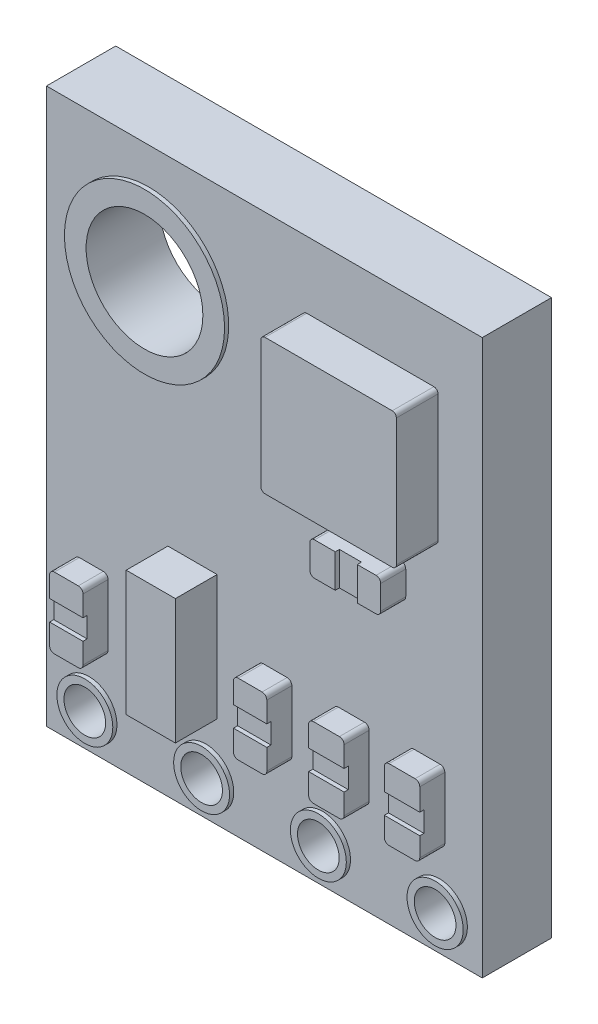
from build123d import *

# Parameters (mm, degrees)
CROQUIS1_W              = 10.45
CROQUIS1_H              = 13.3
CROQUIS1_R              = 1.4
SALIENTE_EXTRUIR1_DEPTH = 1.66
SALIENTE_EXTRUIR2_DEPTH = 1
SALIENTE_EXTRUIR3_DEPTH = 0.6
CROQUIS4_R              = 0.5
CORTAR_EXTRUIR1_DEPTH   = 2
CROQUIS5_W              = 1.18
CROQUIS5_H              = 3
SALIENTE_EXTRUIR4_DEPTH = 1
CROQUIS6_R              = 0.670494612
CROQUIS6_R_2            = 0.5
CROQUIS6_R_3            = 0.673168706
CROQUIS6_R_4            = 1.920139837
CROQUIS6_R_5            = 1.4
SALIENTE_EXTRUIR5_DEPTH = 0.1
CROQUIS7_W              = 0.8
CROQUIS7_H              = 0.488253232
CROQUIS7_W_2            = 0.85
CROQUIS7_W_3            = 0.528941002
CROQUIS7_H_2            = 0.8
CORTAR_EXTRUIR2_DEPTH   = 0.1


with BuildPart() as part:
    # Croquis1 → Saliente-Extruir1 (new body)
    with BuildSketch(Plane.XY):
        Rectangle(CROQUIS1_W, CROQUIS1_H)
        with Locations((-2.775, 3.86)):
            Circle(CROQUIS1_R, mode=Mode.SUBTRACT)
    extrude(amount=SALIENTE_EXTRUIR1_DEPTH)

    # Croquis2 → Saliente-Extruir2 (add)
    with BuildSketch(Plane.XY.offset(1.66)):
        with BuildLine():
            Line((1.014875741, 5.05), (4.064875741, 5.05))
            ThreePointArc((4.064875741, 5.05), (4.13558642, 5.020710678), (4.164875741, 4.95))
            Line((4.164875741, 4.95), (4.164875741, 1.9))
            ThreePointArc((4.164875741, 1.9), (4.13558642, 1.829289322), (4.064875741, 1.8))
            Line((4.064875741, 1.8), (1.014875741, 1.8))
            ThreePointArc((1.014875741, 1.8), (0.944165063, 1.829289322), (0.914875741, 1.9))
            Line((0.914875741, 1.9), (0.914875741, 4.95))
            ThreePointArc((0.914875741, 4.95), (0.944165063, 5.020710678), (1.014875741, 5.05))
        make_face()
    extrude(amount=SALIENTE_EXTRUIR2_DEPTH)

    # Croquis3 → Saliente-Extruir3 (add)
    with BuildSketch(Plane.XY.offset(1.66)):
        with BuildLine():
            Line((0.545086024, -4.450002724), (-0.029222615, -4.450002724))
            ThreePointArc((-0.029222615, -4.450002724), (-0.109016561, -4.41695099), (-0.142068295, -4.337157044))
            Line((-0.142068295, -4.337157044), (-0.142068295, -2.862848405))
            ThreePointArc((-0.142068295, -2.862848405), (-0.109016561, -2.783054459), (-0.029222615, -2.750002724))
            Line((-0.029222615, -2.750002724), (0.545086024, -2.750002724))
            ThreePointArc((0.545086024, -2.750002724), (0.62487997, -2.783054459), (0.657931705, -2.862848405))
            Line((0.657931705, -2.862848405), (0.657931705, -4.337157044))
            ThreePointArc((0.657931705, -4.337157044), (0.62487997, -4.41695099), (0.545086024, -4.450002724))
        make_face()
        with BuildLine():
            Line((-4.549824975, -4.337157044), (-4.549824975, -2.862848405))
            ThreePointArc((-4.549824975, -2.862848405), (-4.516773241, -2.783054459), (-4.436979295, -2.750002724))
            Line((-4.436979295, -2.750002724), (-3.862670656, -2.750002724))
            ThreePointArc((-3.862670656, -2.750002724), (-3.78287671, -2.783054459), (-3.749824975, -2.862848405))
            Line((-3.749824975, -2.862848405), (-3.749824975, -4.337157044))
            ThreePointArc((-3.749824975, -4.337157044), (-3.78287671, -4.41695099), (-3.862670656, -4.450002724))
            Line((-3.862670656, -4.450002724), (-4.436979295, -4.450002724))
            ThreePointArc((-4.436979295, -4.450002724), (-4.516773241, -4.41695099), (-4.549824975, -4.337157044))
        make_face()
        with BuildLine():
            Line((3.58895412, -2.716727386), (4.213262759, -2.716727386))
            ThreePointArc((4.213262759, -2.716727386), (4.293056705, -2.749779121), (4.32610844, -2.829573067))
            Line((4.32610844, -2.829573067), (4.32610844, -4.303881706))
            ThreePointArc((4.32610844, -4.303881706), (4.293056705, -4.383675652), (4.213262759, -4.416727386))
            Line((4.213262759, -4.416727386), (3.58895412, -4.416727386))
            ThreePointArc((3.58895412, -4.416727386), (3.509160174, -4.383675652), (3.47610844, -4.303881706))
            Line((3.47610844, -4.303881706), (3.47610844, -2.829573067))
            ThreePointArc((3.47610844, -2.829573067), (3.509160174, -2.749779121), (3.58895412, -2.716727386))
        make_face()
        with BuildLine():
            Line((1.661189231, -4.337157044), (1.661189231, -2.862848405))
            ThreePointArc((1.661189231, -2.862848405), (1.694240966, -2.783054459), (1.774034912, -2.750002724))
            Line((1.774034912, -2.750002724), (2.398343551, -2.750002724))
            ThreePointArc((2.398343551, -2.750002724), (2.478137497, -2.783054459), (2.511189231, -2.862848405))
            Line((2.511189231, -2.862848405), (2.511189231, -4.337157044))
            ThreePointArc((2.511189231, -4.337157044), (2.478137497, -4.41695099), (2.398343551, -4.450002724))
            Line((2.398343551, -4.450002724), (1.774034912, -4.450002724))
            ThreePointArc((1.774034912, -4.450002724), (1.694240966, -4.41695099), (1.661189231, -4.337157044))
        make_face()
        with BuildLine():
            Line((1.689875741, 0.350979107), (1.689875741, 0.925287746))
            ThreePointArc((1.689875741, 0.925287746), (1.722927476, 1.005081692), (1.802721422, 1.038133426))
            Line((1.802721422, 1.038133426), (3.277030061, 1.038133426))
            ThreePointArc((3.277030061, 1.038133426), (3.356824007, 1.005081692), (3.389875741, 0.925287746))
            Line((3.389875741, 0.925287746), (3.389875741, 0.350979107))
            ThreePointArc((3.389875741, 0.350979107), (3.356824007, 0.271185161), (3.277030061, 0.238133426))
            Line((3.277030061, 0.238133426), (1.802721422, 0.238133426))
            ThreePointArc((1.802721422, 0.238133426), (1.722927476, 0.271185161), (1.689875741, 0.350979107))
        make_face()
    extrude(amount=SALIENTE_EXTRUIR3_DEPTH)

    # Croquis4 → Cortar-Extruir1 (cut)
    with BuildSketch(Plane.XY.offset(1.66)):
        with Locations((4.194245203, -5.773988592)):
            Circle(CROQUIS4_R)
        with Locations((1.394245203, -5.773988592)):
            Circle(CROQUIS4_R)
        with Locations((-1.405754797, -5.773988592)):
            Circle(CROQUIS4_R)
        with Locations((-4.205754797, -5.773988592)):
            Circle(CROQUIS4_R)
    extrude(amount=-CORTAR_EXTRUIR1_DEPTH, mode=Mode.SUBTRACT)

    # Croquis5 → Saliente-Extruir4 (add)
    with BuildSketch(Plane.XY.offset(1.66)):
        with Locations((-1.72406111, -2.950002724)):
            Rectangle(CROQUIS5_W, CROQUIS5_H)
    extrude(amount=SALIENTE_EXTRUIR4_DEPTH)

    # Croquis6 → Saliente-Extruir5 (add)
    with BuildSketch(Plane.XY.offset(1.66)):
        with Locations((-4.205754797, -5.773988592)):
            Circle(CROQUIS6_R)
        with Locations((-4.205754797, -5.773988592)):
            Circle(CROQUIS6_R_2, mode=Mode.SUBTRACT)
        with Locations((-1.405754797, -5.773988592)):
            Circle(CROQUIS6_R)
        with Locations((-1.405754797, -5.773988592)):
            Circle(CROQUIS6_R_2, mode=Mode.SUBTRACT)
        with Locations((1.394245203, -5.773988592)):
            Circle(CROQUIS6_R)
        with Locations((1.394245203, -5.773988592)):
            Circle(CROQUIS6_R_2, mode=Mode.SUBTRACT)
        with Locations((4.194245203, -5.773988592)):
            Circle(CROQUIS6_R_3)
        with Locations((4.194245203, -5.773988592)):
            Circle(CROQUIS6_R_2, mode=Mode.SUBTRACT)
        with Locations((-2.775, 3.86)):
            Circle(CROQUIS6_R_4)
        with Locations((-2.775, 3.86)):
            Circle(CROQUIS6_R_5, mode=Mode.SUBTRACT)
    extrude(amount=SALIENTE_EXTRUIR5_DEPTH)

    # Croquis7 → Cortar-Extruir2 (cut)
    with BuildSketch(Plane.XY.offset(2.26)):
        with Locations((-4.149824975, -3.600867586)):
            Rectangle(CROQUIS7_W, CROQUIS7_H)
        with Locations((0.257931705, -3.600867586)):
            Rectangle(CROQUIS7_W, CROQUIS7_H)
        with Locations((2.086189231, -3.600867586)):
            Rectangle(CROQUIS7_W_2, CROQUIS7_H)
        with Locations((3.90110844, -3.600867586)):
            Rectangle(CROQUIS7_W_2, CROQUIS7_H)
        with Locations((2.563329468, 0.638133426)):
            Rectangle(CROQUIS7_W_3, CROQUIS7_H_2)
    extrude(amount=-CORTAR_EXTRUIR2_DEPTH, mode=Mode.SUBTRACT)


solid = part.part
